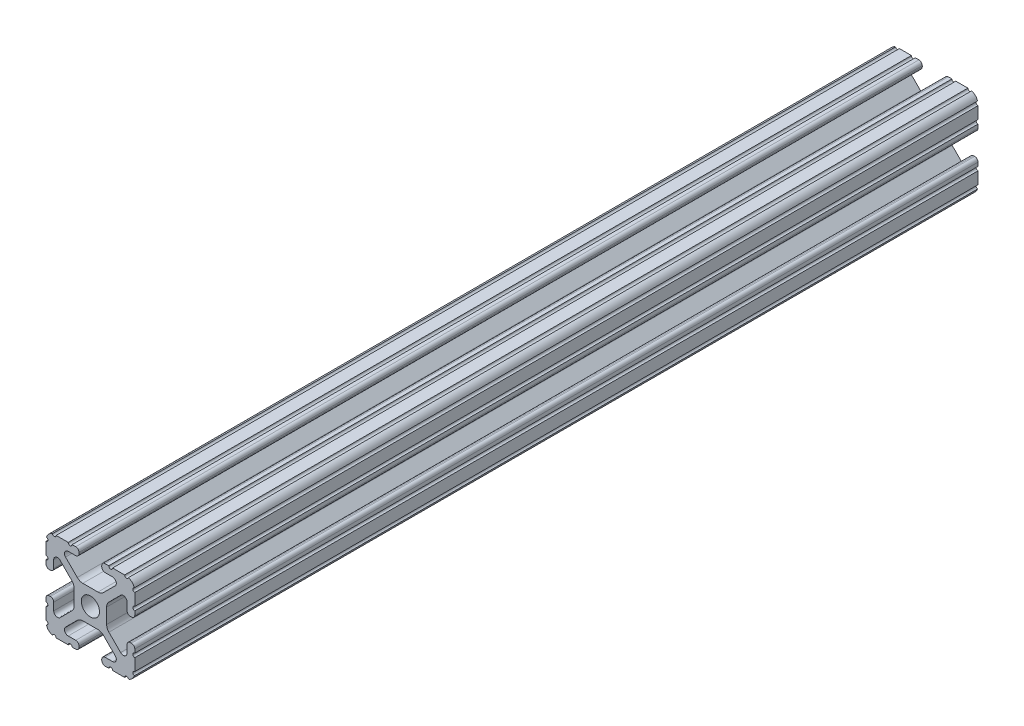
from build123d import *

# Parameters (mm, degrees)
BOSS_EXTRUDE1_DEPTH     = 120.65
SKETCH5_R               = 0.55245
CUT_EXTRUDE1_DEPTH      = 121.65
CUT_EXTRUDE1_DEPTH_BACK = 121.65


with BuildPart() as part:
    # Sketch4 → Boss-Extrude1 (new body, symmetric)
    with BuildSketch(Plane.XY):
        with BuildLine():
            Line((4.190365, -12.7), (10.11729625, -12.7))
            ThreePointArc((10.11729625, -12.7), (11.943543585, -11.943543585), (12.7, -10.11729625))
            Line((12.7, -10.11729625), (12.7, -4.190365))
            ThreePointArc((12.7, -4.190365), (12.42492494, -3.52627506), (11.760835, -3.2512))
            Line((11.760835, -3.2512), (11.429365, -3.2512))
            ThreePointArc((11.429365, -3.2512), (10.76527506, -3.52627506), (10.4902, -4.190365))
            Line((10.4902, -4.190365), (10.4902, -6.348478019))
            ThreePointArc((10.4902, -6.348478019), (9.830707141, -7.335478831), (8.666460301, -7.103895736))
            Line((8.666460301, -7.103895736), (5.299899128, -3.737334563))
            ThreePointArc((5.299899128, -3.737334563), (4.817571085, -3.015479634), (4.6482, -2.16399369))
            Line((4.6482, -2.16399369), (4.6482, 0))
            Line((4.6482, 0), (2.6035, 0))
            ThreePointArc((2.6035, 0), (1.840952505, -1.840952505), (0, -2.6035))
            Line((0, -2.6035), (0, -4.6482))
            Line((0, -4.6482), (2.16399369, -4.6482))
            ThreePointArc((2.16399369, -4.6482), (3.015479634, -4.817571085), (3.737334563, -5.299899128))
            Line((3.737334563, -5.299899128), (7.103895736, -8.666460301))
            ThreePointArc((7.103895736, -8.666460301), (7.335478831, -9.830707141), (6.348478019, -10.4902))
            Line((6.348478019, -10.4902), (4.190365, -10.4902))
            ThreePointArc((4.190365, -10.4902), (3.52627506, -10.76527506), (3.2512, -11.429365))
            Line((3.2512, -11.429365), (3.2512, -11.760835))
            ThreePointArc((3.2512, -11.760835), (3.52627506, -12.42492494), (4.190365, -12.7))
        make_face()
    extrude(amount=BOSS_EXTRUDE1_DEPTH, both=True)

    # Sketch5 → Cut-Extrude1 (cut, two sides)
    with BuildSketch(Plane.XY) as cut_extrude1_sk:
        with Locations((10.356153152, -12.7)):
            Circle(SKETCH5_R)
        with Locations((5.796028019, -12.7)):
            Circle(SKETCH5_R)
        with Locations((12.7, -10.356153152)):
            Circle(SKETCH5_R)
        with Locations((12.7, -5.796028019)):
            Circle(SKETCH5_R)
    extrude(amount=CUT_EXTRUDE1_DEPTH, mode=Mode.SUBTRACT)
    extrude(cut_extrude1_sk.sketch, amount=-CUT_EXTRUDE1_DEPTH_BACK, mode=Mode.SUBTRACT)

    # Mirror1: part across plane


with BuildPart() as part_1:
    add(part.part)
    add(part.part.mirror(Plane(origin=(0, 0, 0), x_dir=(0, 0, 1), z_dir=(1, 0, 0))))

    # Mirror2: part across plane


with BuildPart() as part_2:
    add(part_1.part)
    add(part_1.part.mirror(Plane.ZX))


solid = part_2.part
